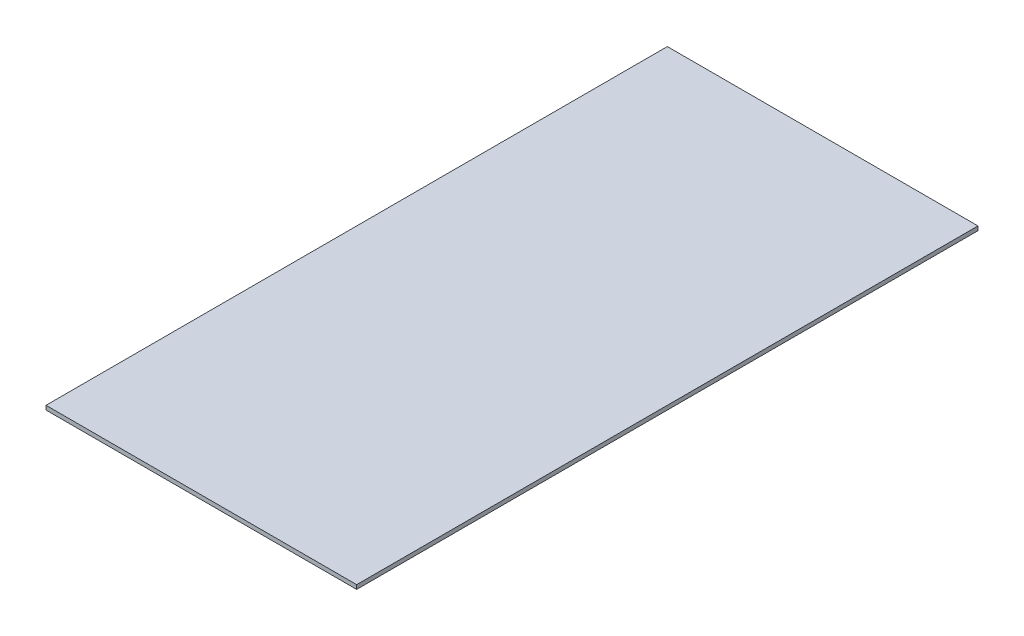
from build123d import *

# Parameters (mm, degrees)
SKETCH_1_W      = 900
SKETCH_1_H      = 12
EXTRUDE_1_DEPTH = 1800


with BuildPart() as part:
    # ｽｹｯﾁ1 → ﾎﾞｽ - 押し出し1 (new body)
    with BuildSketch(Plane.XY):
        with Locations((192.857142857, 267.588039867)):
            Rectangle(SKETCH_1_W, SKETCH_1_H)
    extrude(amount=EXTRUDE_1_DEPTH)


solid = part.part
